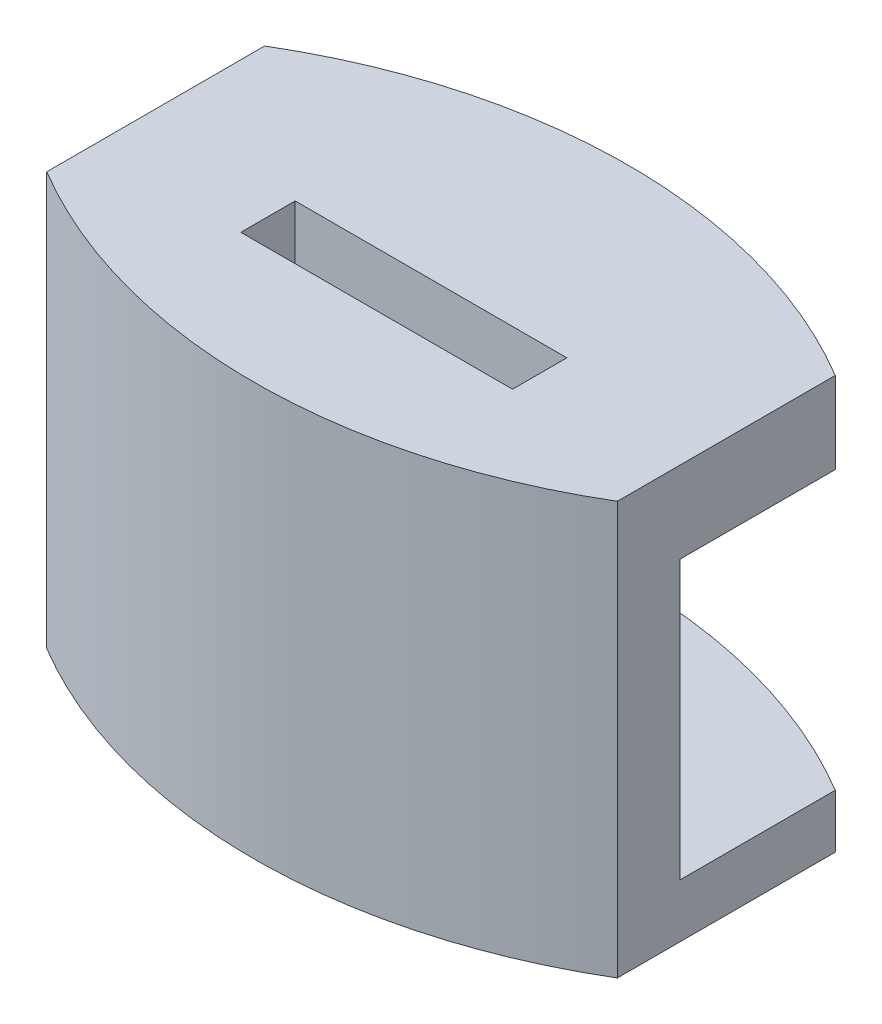
from build123d import *

# Parameters (mm, degrees)
BOSS_EXTRUDE1_DEPTH     = 15.21999998
SKETCH2_W               = 36.809677156
SKETCH2_H               = 26.071604974
BOSS_EXTRUDE2_DEPTH     = 3
SKETCH3_W               = 36.809677156
SKETCH3_H               = 26.071604974
BOSS_EXTRUDE3_DEPTH     = 2
SKETCH4_W               = 60.36112228
SKETCH4_H               = 157.574347664
SKETCH4_W_2             = 21
SKETCH4_H_2             = 111.767475737
CUT_EXTRUDE1_DEPTH      = 38.576
SKETCH5_W               = 10
SKETCH5_H               = 2
CUT_EXTRUDE2_DEPTH      = 38.576
SKETCH6_W               = 35.571492448
SKETCH6_H               = 20.32
CUT_EXTRUDE3_DEPTH      = 25.876
CUT_EXTRUDE3_DEPTH_BACK = 20.32
SKETCH7_W               = 25.588268566
SKETCH7_H               = 5
CUT_EXTRUDE4_DEPTH      = 25.876
SKETCH10_R              = 48.677475689
SKETCH10_R_2            = 20.5
CUT_EXTRUDE5_DEPTH      = 14.478
CUT_EXTRUDE5_DEPTH_BACK = 169.64
BOSS_EXTRUDE4_DEPTH     = 15.208
SKETCH12_W              = 30.501346117
SKETCH12_H              = 25.675497492
CUT_EXTRUDE8_DEPTH      = 8.604
CUT_EXTRUDE8_DEPTH_BACK = 0.0254
SKETCH13_W              = 21
SKETCH13_H              = 10.21999998
CUT_EXTRUDE9_DEPTH      = 8.604


with BuildPart() as part:
    # Sketch1 → Boss-Extrude1 (new body)
    with BuildSketch(Plane(origin=(0, 0, 0), x_dir=(1, 0, 0), z_dir=(0, 1, 0))):
        with BuildLine():
            Line((18.404838578, -7.300000132), (-18.404838578, -7.300000132))
            Line((-18.404838578, -7.300000132), (-18.404838578, 7.300000132))
            Line((-18.404838578, 7.300000132), (-18.404838578, 11.471604964))
            ThreePointArc((-18.404838578, 11.471604964), (0, 0), (18.404838578, 11.471604964))
            Line((18.404838578, 11.471604964), (18.404838578, 7.300000132))
            Line((18.404838578, 7.300000132), (18.404838578, -7.300000132))
        make_face()
    extrude(amount=BOSS_EXTRUDE1_DEPTH)

    # Sketch2 → Boss-Extrude2 (add)
    with BuildSketch(Plane(origin=(0, 15.21999998, 0), x_dir=(1, 0, 0), z_dir=(0, 1, 0))):
        with Locations((0, 5.735802355)):
            Rectangle(SKETCH2_W, SKETCH2_H)
    extrude(amount=-BOSS_EXTRUDE2_DEPTH)

    # Sketch3 → Boss-Extrude3 (add)
    with BuildSketch(Plane.XZ):
        with Locations((0, -5.735802355)):
            Rectangle(SKETCH3_W, SKETCH3_H)
    extrude(amount=-BOSS_EXTRUDE3_DEPTH)

    # Sketch4 → Cut-Extrude1 (cut)
    with BuildSketch(Plane.XZ):
        with Locations((0, -3.625194089)):
            Rectangle(SKETCH4_W, SKETCH4_H)
        with Locations((0, -3.62519409)):
            Rectangle(SKETCH4_W_2, SKETCH4_H_2, mode=Mode.SUBTRACT)
    extrude(amount=-CUT_EXTRUDE1_DEPTH, mode=Mode.SUBTRACT)

    # Sketch5 → Cut-Extrude2 (cut)
    with BuildSketch(Plane.XZ.offset(-12.21999998)):
        with Locations((0, -3.2352)):
            Rectangle(SKETCH5_W, SKETCH5_H)
    extrude(amount=-CUT_EXTRUDE2_DEPTH, mode=Mode.SUBTRACT)

    # Sketch6 → Cut-Extrude3 (cut, two sides)
    with BuildSketch(Plane.XZ.offset(-12.21999998)) as cut_extrude3_sk:
        with Locations((0, -18.771604842)):
            Rectangle(SKETCH6_W, SKETCH6_H)
    extrude(amount=CUT_EXTRUDE3_DEPTH, mode=Mode.SUBTRACT)
    extrude(cut_extrude3_sk.sketch, amount=-CUT_EXTRUDE3_DEPTH_BACK, mode=Mode.SUBTRACT)

    # Sketch7 → Cut-Extrude4 (cut)
    with BuildSketch(Plane(origin=(0, 15.21999998, 0), x_dir=(1, 0, 0), z_dir=(0, 1, 0))):
        with Locations((0, -7.300000132)):
            Rectangle(SKETCH7_W, SKETCH7_H)
    extrude(amount=-CUT_EXTRUDE4_DEPTH, mode=Mode.SUBTRACT)

    # Sketch10 → Cut-Extrude5 (cut, two sides)
    with BuildSketch(Plane(origin=(0, 15.21999998, 0), x_dir=(1, 0, 0), z_dir=(0, 1, 0))) as cut_extrude5_sk:
        with Locations((0, 18.199999842)):
            Circle(SKETCH10_R)
        with Locations((0, 18.199999842)):
            Circle(SKETCH10_R_2, mode=Mode.SUBTRACT)
    extrude(amount=CUT_EXTRUDE5_DEPTH, mode=Mode.SUBTRACT)
    extrude(cut_extrude5_sk.sketch, amount=-CUT_EXTRUDE5_DEPTH_BACK, mode=Mode.SUBTRACT)

    # Sketch11 → Boss-Extrude4 (add)
    with BuildSketch(Plane(origin=(0, 15.21999998, 0), x_dir=(1, 0, 0), z_dir=(0, 1, 0))):
        with BuildLine():
            Line((-10.5, 8.611604842), (10.5, 8.611604842))
            ThreePointArc((10.5, 8.611604842), (0, 11.50478798), (-10.5, 8.611604842))
        make_face()
    extrude(amount=-BOSS_EXTRUDE4_DEPTH)

    # Sketch12 → Cut-Extrude8 (cut, two sides)
    with BuildSketch(Plane.XZ) as cut_extrude8_sk:
        with Locations((1.361590216, -5.971942541)):
            Rectangle(SKETCH12_W, SKETCH12_H)
    extrude(amount=CUT_EXTRUDE8_DEPTH, mode=Mode.SUBTRACT)
    extrude(cut_extrude8_sk.sketch, amount=-CUT_EXTRUDE8_DEPTH_BACK, mode=Mode.SUBTRACT)

    # Sketch13 → Cut-Extrude9 (cut)
    with BuildSketch(Plane.XY.offset(-8.611604842)):
        with Locations((0, 7.10999999)):
            Rectangle(SKETCH13_W, SKETCH13_H)
    extrude(amount=-CUT_EXTRUDE9_DEPTH, mode=Mode.SUBTRACT)


solid = part.part
